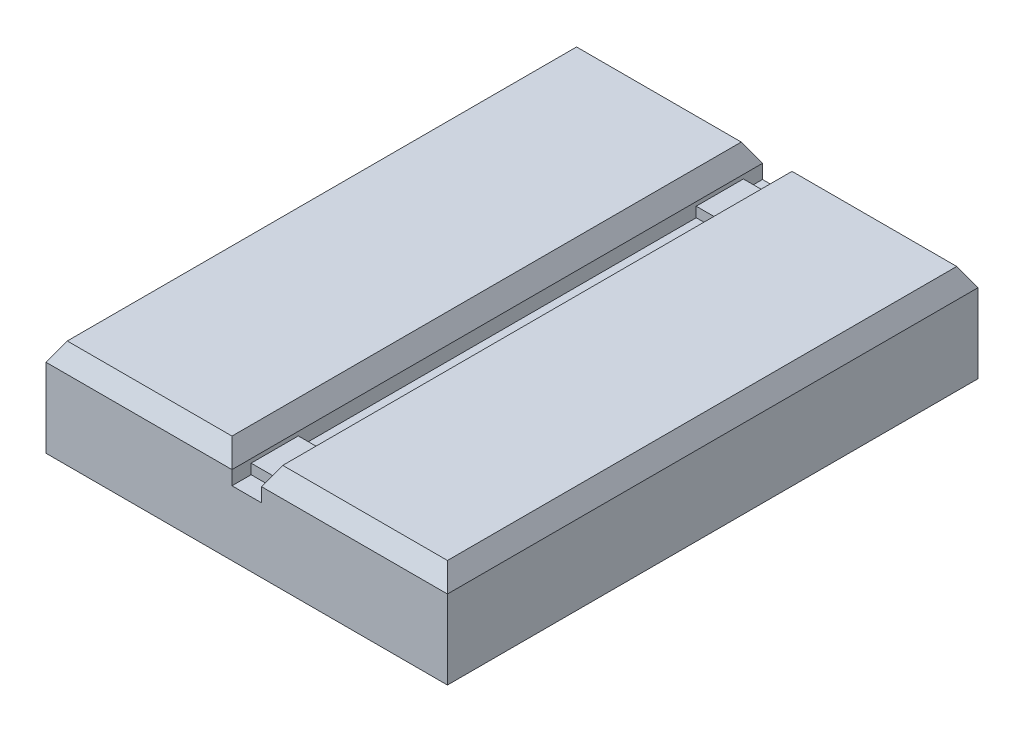
from build123d import *

# Parameters (mm, degrees)
BOSS_EXTRUDE1_DEPTH   = 22.86
CHAMFER1_SIZE         = 1.5875
CHAMFER1_SIZE2        = 0.916543552
CHAMFER1_PART_2_SIZE  = 1.5875
CHAMFER1_PART_2_SIZE2 = 0.916543552
CHAMFER1_PART_3_SIZE  = 1.5875
CHAMFER1_PART_3_SIZE2 = 0.916543552
CHAMFER1_PART_4_SIZE  = 1.5875
CHAMFER1_PART_4_SIZE2 = 0.916543552
CHAMFER1_PART_5_SIZE  = 1.5875
CHAMFER1_PART_5_SIZE2 = 0.916543552
CHAMFER1_PART_6_SIZE  = 1.5875
CHAMFER1_PART_6_SIZE2 = 0.916543552
BOSS_EXTRUDE2_START   = 17.145
SKETCH2_W             = 2.54
SKETCH2_H             = 0.8636
BOSS_EXTRUDE2_DEPTH   = 4.064


with BuildPart() as part:
    # Sketch1 → Boss-Extrude1 (new body, symmetric)
    with BuildSketch(Plane.XY):
        Polygon((-17.2974, 0), (17.2974, 0), (17.2974, 8.382), (1.27, 8.382), (1.27, 5.588), (-1.27, 5.588), (-1.27, 8.382), (-17.2974, 8.382), align=None)
    extrude(amount=BOSS_EXTRUDE1_DEPTH, both=True)

    # Chamfer1
    chamfer1_edges = [part.edges().sort_by_distance(p)[0] for p in [
        (9.2837, 8.382, -22.86),
        (-9.2837, 8.382, -22.86),
    ]]
    chamfer1_side = [part.faces().sort_by_distance(p)[0] for p in [
        (0, 4.120904666, -22.86),
    ]]
    chamfer(chamfer1_edges, length=CHAMFER1_SIZE, length2=CHAMFER1_SIZE2, reference=chamfer1_side[0])

    # Chamfer1 part 2
    chamfer1_part_2_edges = [part.edges().sort_by_distance(p)[0] for p in [
        (17.2974, 8.382, 0),
    ]]
    chamfer1_part_2_side = [part.faces().sort_by_distance(p)[0] for p in [
        (17.2974, 4.191, 0),
    ]]
    chamfer(chamfer1_part_2_edges, length=CHAMFER1_PART_2_SIZE, length2=CHAMFER1_PART_2_SIZE2, reference=chamfer1_part_2_side[0])

    # Chamfer1 part 3
    chamfer1_part_3_edges = [part.edges().sort_by_distance(p)[0] for p in [
        (-17.2974, 8.382, 0),
    ]]
    chamfer1_part_3_side = [part.faces().sort_by_distance(p)[0] for p in [
        (-17.2974, 4.191, 0),
    ]]
    chamfer(chamfer1_part_3_edges, length=CHAMFER1_PART_3_SIZE, length2=CHAMFER1_PART_3_SIZE2, reference=chamfer1_part_3_side[0])

    # Chamfer1 part 4
    chamfer1_part_4_edges = [part.edges().sort_by_distance(p)[0] for p in [
        (-1.27, 8.382, 0),
    ]]
    chamfer1_part_4_side = [part.faces().sort_by_distance(p)[0] for p in [
        (-1.27, 6.985, 0),
    ]]
    chamfer(chamfer1_part_4_edges, length=CHAMFER1_PART_4_SIZE, length2=CHAMFER1_PART_4_SIZE2, reference=chamfer1_part_4_side[0])

    # Chamfer1 part 5
    chamfer1_part_5_edges = [part.edges().sort_by_distance(p)[0] for p in [
        (1.27, 8.382, 0),
    ]]
    chamfer1_part_5_side = [part.faces().sort_by_distance(p)[0] for p in [
        (1.27, 6.985, 0),
    ]]
    chamfer(chamfer1_part_5_edges, length=CHAMFER1_PART_5_SIZE, length2=CHAMFER1_PART_5_SIZE2, reference=chamfer1_part_5_side[0])

    # Chamfer1 part 6
    chamfer1_part_6_edges = [part.edges().sort_by_distance(p)[0] for p in [
        (-9.2837, 8.382, 22.86),
        (9.2837, 8.382, 22.86),
    ]]
    chamfer1_part_6_side = [part.faces().sort_by_distance(p)[0] for p in [
        (0, 4.120904666, 22.86),
    ]]
    chamfer(chamfer1_part_6_edges, length=CHAMFER1_PART_6_SIZE, length2=CHAMFER1_PART_6_SIZE2, reference=chamfer1_part_6_side[0])

    # Sketch2 → Boss-Extrude2 (add)
    with BuildSketch(Plane.XY.offset(BOSS_EXTRUDE2_START)):
        with Locations((0, 6.0198)):
            Rectangle(SKETCH2_W, SKETCH2_H)
    boss_extrude2 = extrude(amount=BOSS_EXTRUDE2_DEPTH)

    # Mirror1: Boss-Extrude2 across plane
    add(boss_extrude2.mirror(Plane.XY))


solid = part.part
